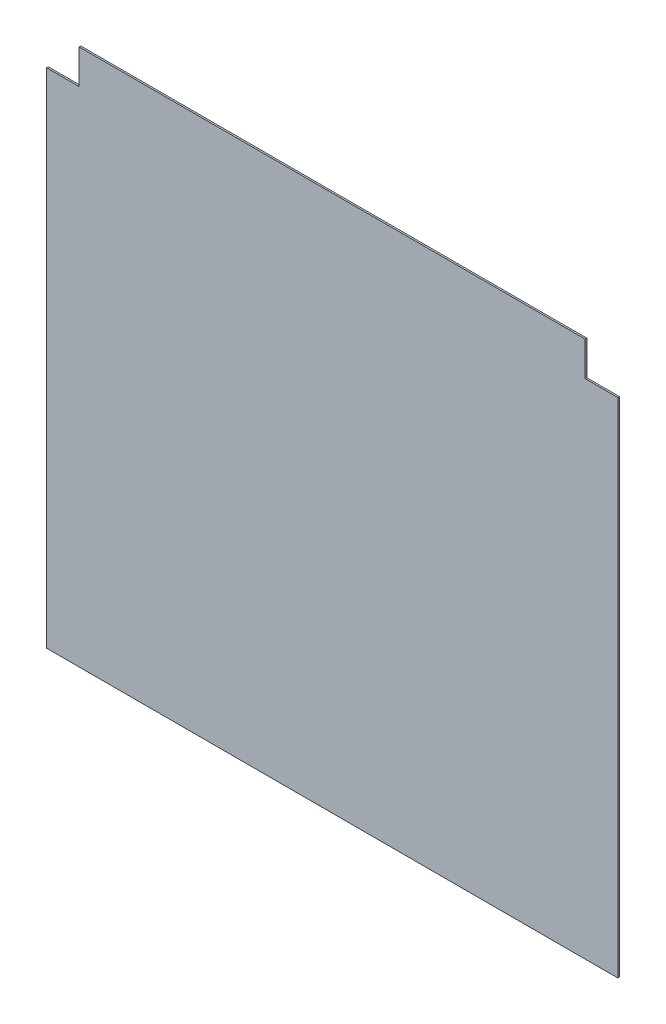
from build123d import *

# Parameters (mm, degrees)
EXTRUDE_1_DEPTH = 1


with BuildPart() as part:
    # 스케치1 → 보스-돌출1 (new body)
    with BuildSketch(Plane.XY):
        Polygon((0, 0), (350, 0), (350, 308), (330, 308), (330, 329), (20, 329), (20, 308), (0, 308), align=None)
    extrude(amount=EXTRUDE_1_DEPTH)


solid = part.part
